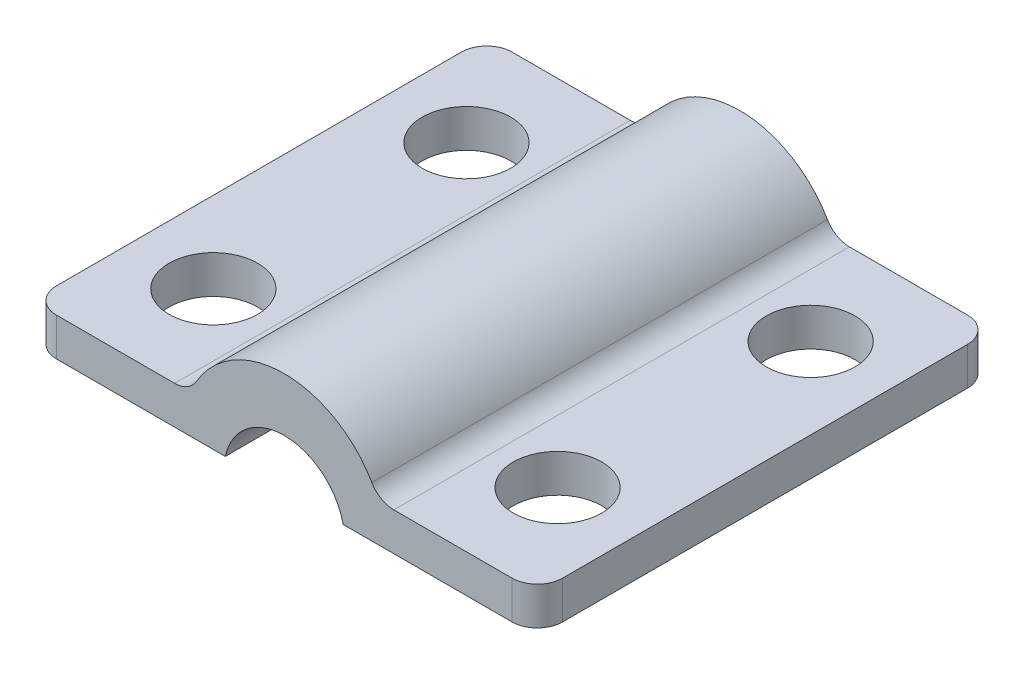
from build123d import *

# Parameters (mm, degrees)
BOSS_EXTRUDE1_DEPTH = 9
CUT_EXTRUDE1_REACH  = 20
SKETCH3_R           = 2.38125
CUT_EXTRUDE2_REACH  = 3.5
SKETCH4_R           = 1.75
FILLET1_R           = 1
FILLET2_R           = 1


with BuildPart() as part:
    # Sketch1 → Boss-Extrude1 (new body, symmetric)
    with BuildSketch(Plane.XY):
        with BuildLine():
            Line((-10, 0), (-4, 0))
            ThreePointArc((-4, 0), (-3.92634671, 0.76406905), (-3.708099244, 1.5))
            Line((-3.708099244, 1.5), (-10, 1.5))
            Line((-10, 1.5), (-10, 0))
        make_face()
        with BuildLine():
            Line((-4, 0), (4, 0))
            ThreePointArc((4, 0), (3.92634671, 0.76406905), (3.708099244, 1.5))
            Line((3.708099244, 1.5), (-3.708099244, 1.5))
            ThreePointArc((-3.708099244, 1.5), (-3.92634671, 0.76406905), (-4, 0))
        make_face()
        with BuildLine():
            ThreePointArc((3.708099244, 1.5), (3.92634671, 0.76406905), (4, 0))
            Line((4, 0), (10, 0))
            Line((10, 0), (10, 1.5))
            Line((10, 1.5), (3.708099244, 1.5))
        make_face()
        with BuildLine():
            Line((-3.708099244, 1.5), (3.708099244, 1.5))
            ThreePointArc((3.708099244, 1.5), (0, 4), (-3.708099244, 1.5))
        make_face()
    extrude(amount=BOSS_EXTRUDE1_DEPTH, both=True)

    # Sketch3 → Cut-Extrude1 (cut, up to next)
    with BuildSketch(Plane.XY.offset(9), mode=Mode.PRIVATE) as cut_extrude1_sk1:
        with Locations((0, -0.5)):
            Circle(SKETCH3_R)
    cut_extrude1_tool1 = extrude(cut_extrude1_sk1.sketch, amount=-CUT_EXTRUDE1_REACH, mode=Mode.PRIVATE) & part.part
    add(cut_extrude1_tool1.solids().sort_by_distance((0, -0.5, 9))[0], mode=Mode.SUBTRACT)

    # Sketch4 → Cut-Extrude2 (cut, up to next)
    with BuildSketch(Plane(origin=(0, 1.5, 0), x_dir=(1, 0, 0), z_dir=(0, 1, 0)), mode=Mode.PRIVATE) as cut_extrude2_sk1:
        with Locations((-6.8, 5)):
            Circle(SKETCH4_R)
    cut_extrude2_tool1 = extrude(cut_extrude2_sk1.sketch, amount=-CUT_EXTRUDE2_REACH, mode=Mode.PRIVATE) & part.part
    add(cut_extrude2_tool1.solids().sort_by_distance((-6.8, 1.5, -5))[0], mode=Mode.SUBTRACT)
    # Sketch4 → Cut-Extrude2 (cut, up to next)
    with BuildSketch(Plane(origin=(0, 1.5, 0), x_dir=(1, 0, 0), z_dir=(0, 1, 0)), mode=Mode.PRIVATE) as cut_extrude2_sk2:
        with Locations((6.8, 5)):
            Circle(SKETCH4_R)
    cut_extrude2_tool2 = extrude(cut_extrude2_sk2.sketch, amount=-CUT_EXTRUDE2_REACH, mode=Mode.PRIVATE) & part.part
    add(cut_extrude2_tool2.solids().sort_by_distance((6.8, 1.5, -5))[0], mode=Mode.SUBTRACT)
    # Sketch4 → Cut-Extrude2 (cut, up to next)
    with BuildSketch(Plane(origin=(0, 1.5, 0), x_dir=(1, 0, 0), z_dir=(0, 1, 0)), mode=Mode.PRIVATE) as cut_extrude2_sk3:
        with Locations((6.8, -5)):
            Circle(SKETCH4_R)
    cut_extrude2_tool3 = extrude(cut_extrude2_sk3.sketch, amount=-CUT_EXTRUDE2_REACH, mode=Mode.PRIVATE) & part.part
    add(cut_extrude2_tool3.solids().sort_by_distance((6.8, 1.5, 5))[0], mode=Mode.SUBTRACT)
    # Sketch4 → Cut-Extrude2 (cut, up to next)
    with BuildSketch(Plane(origin=(0, 1.5, 0), x_dir=(1, 0, 0), z_dir=(0, 1, 0)), mode=Mode.PRIVATE) as cut_extrude2_sk4:
        with Locations((-6.8, -5)):
            Circle(SKETCH4_R)
    cut_extrude2_tool4 = extrude(cut_extrude2_sk4.sketch, amount=-CUT_EXTRUDE2_REACH, mode=Mode.PRIVATE) & part.part
    add(cut_extrude2_tool4.solids().sort_by_distance((-6.8, 1.5, 5))[0], mode=Mode.SUBTRACT)

    # Fillet1
    fillet1_edges = [part.edges().sort_by_distance(p)[0] for p in [
        (10, 0.75, -9),
        (-10, 0.75, -9),
        (-10, 0.75, 9),
        (10, 0.75, 9),
    ]]
    fillet(fillet1_edges, radius=FILLET1_R)

    # Fillet2
    fillet2_edges = [part.edges().sort_by_distance(p)[0] for p in [
        (-3.708099244, 1.5, 0),
        (3.708099244, 1.5, 0),
    ]]
    fillet(fillet2_edges, radius=FILLET2_R)


solid = part.part
